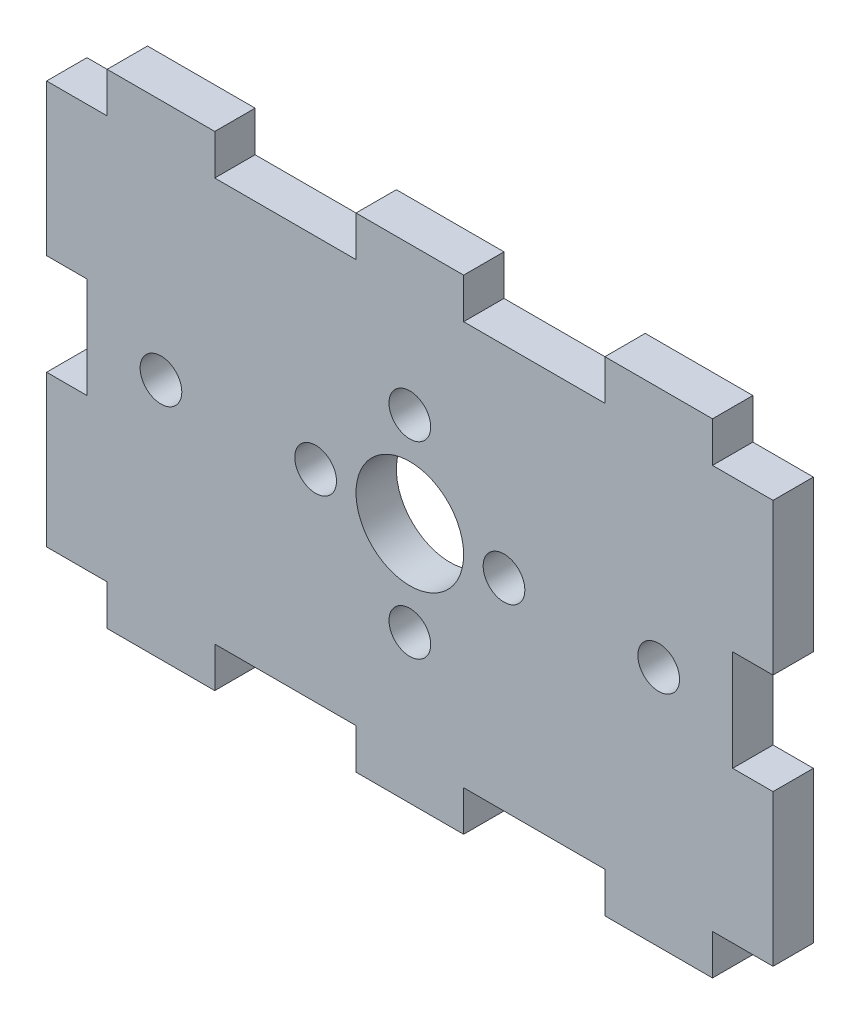
from build123d import *

# Parameters (mm, degrees)
SKETCH_1_R      = 1.55
SKETCH_1_R_2    = 4
EXTRUDE_1_DEPTH = 3


with BuildPart() as part:
    # 草图1 → 凸台-拉伸1 (new body)
    with BuildSketch(Plane.XY):
        Polygon((3214.80265522, 1769.419217818), (3225.30265522, 1769.419217818), (3225.30265522, 1772.419217818), (3233.30265522, 1772.419217818), (3233.30265522, 1769.419217818), (3243.80265522, 1769.419217818), (3243.80265522, 1772.419217818), (3251.80265522, 1772.419217818), (3251.80265522, 1769.419217818), (3256.30265522, 1769.419217818), (3256.30265522, 1758.169217818), (3253.30265522, 1758.169217818), (3253.30265522, 1750.669217818), (3256.30265522, 1750.669217818), (3256.30265522, 1739.419217818), (3251.80265522, 1739.419217818), (3251.80265522, 1736.419217818), (3243.80265522, 1736.419217818), (3243.80265522, 1739.419217818), (3233.30265522, 1739.419217818), (3233.30265522, 1736.419217818), (3225.30265522, 1736.419217818), (3225.30265522, 1739.419217818), (3214.80265522, 1739.419217818), (3214.80265522, 1736.419217818), (3206.80265522, 1736.419217818), (3206.80265522, 1739.419217818), (3202.30265522, 1739.419217818), (3202.30265522, 1750.669217818), (3205.30265522, 1750.669217818), (3205.30265522, 1758.169217818), (3202.30265522, 1758.169217818), (3202.30265522, 1769.419217818), (3206.80265522, 1769.419217818), (3206.80265522, 1772.419217818), (3214.80265522, 1772.419217818), align=None)
        with Locations((3236.30265522, 1754.419217818)):
            Circle(SKETCH_1_R, mode=Mode.SUBTRACT)
        with Locations((3229.30265522, 1761.419217818)):
            Circle(SKETCH_1_R, mode=Mode.SUBTRACT)
        with Locations((3222.30265522, 1754.419217818)):
            Circle(SKETCH_1_R, mode=Mode.SUBTRACT)
        with Locations((3229.30265522, 1747.419217818)):
            Circle(SKETCH_1_R, mode=Mode.SUBTRACT)
        with Locations((3229.30265522, 1754.419217818)):
            Circle(SKETCH_1_R_2, mode=Mode.SUBTRACT)
        with Locations((3247.80265522, 1754.419217818)):
            Circle(SKETCH_1_R, mode=Mode.SUBTRACT)
        with Locations((3210.80265522, 1754.419217818)):
            Circle(SKETCH_1_R, mode=Mode.SUBTRACT)
    extrude(amount=EXTRUDE_1_DEPTH)


solid = part.part
